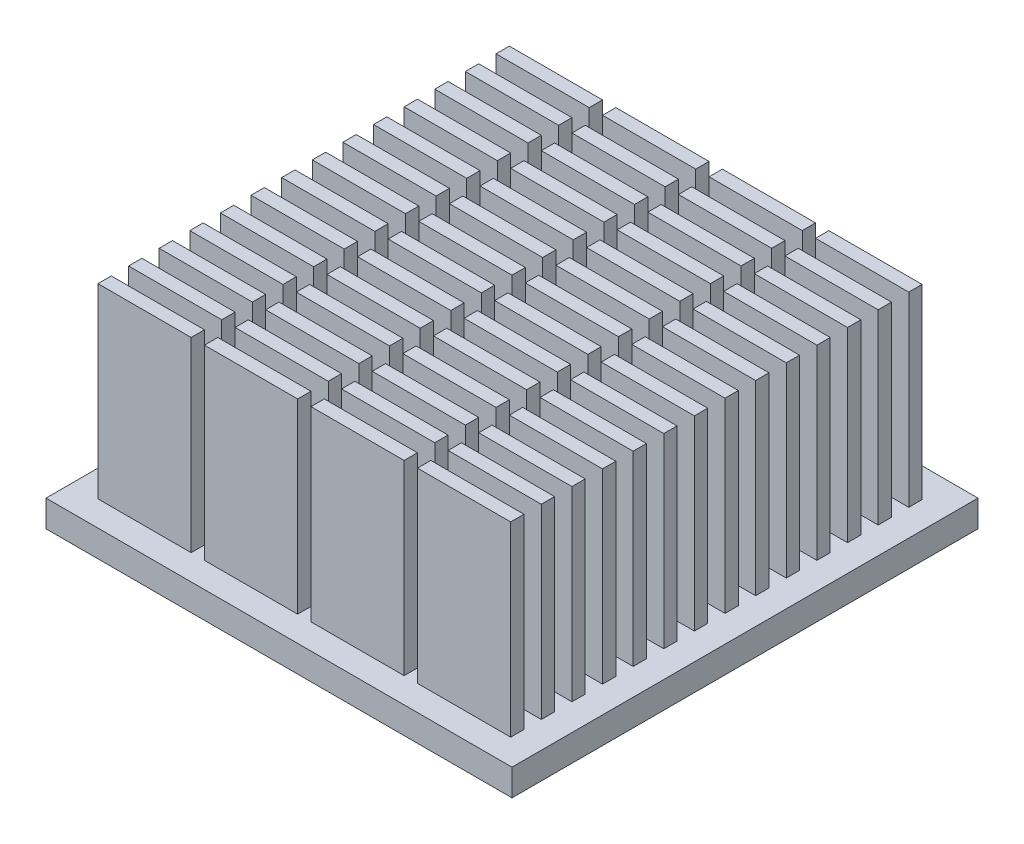
from build123d import *

# Parameters (mm, degrees)
SKETCH1_W           = 35
SKETCH1_H           = 35
BOSS_EXTRUDE1_DEPTH = 2
SKETCH2_W           = 7
SKETCH2_H           = 1
BOSS_EXTRUDE2_DEPTH = 14


with BuildPart() as part:
    # Sketch1 → Boss-Extrude1 (new body)
    with BuildSketch(Plane(origin=(0, 0, 0), x_dir=(1, 0, 0), z_dir=(0, 1, 0))):
        Rectangle(SKETCH1_W, SKETCH1_H)
    extrude(amount=BOSS_EXTRUDE1_DEPTH)

    # Sketch2 → Boss-Extrude2 (add)
    with BuildSketch(Plane(origin=(0, 2, 0), x_dir=(1, 0, 0), z_dir=(0, 1, 0))):
        with Locations((-12, -1.3)):
            Rectangle(SKETCH2_W, SKETCH2_H)
        with Locations((-12, 1)):
            Rectangle(SKETCH2_W, SKETCH2_H)
        with Locations((-4, 1)):
            Rectangle(SKETCH2_W, SKETCH2_H)
        with Locations((4, 1)):
            Rectangle(SKETCH2_W, SKETCH2_H)
        with Locations((12, 1)):
            Rectangle(SKETCH2_W, SKETCH2_H)
        with Locations((-4, -1.3)):
            Rectangle(SKETCH2_W, SKETCH2_H)
        with Locations((4, -1.3)):
            Rectangle(SKETCH2_W, SKETCH2_H)
        with Locations((12, -1.3)):
            Rectangle(SKETCH2_W, SKETCH2_H)
        with Locations((-12, -3.6)):
            Rectangle(SKETCH2_W, SKETCH2_H)
        with Locations((-4, -3.6)):
            Rectangle(SKETCH2_W, SKETCH2_H)
        with Locations((4, -3.6)):
            Rectangle(SKETCH2_W, SKETCH2_H)
        with Locations((12, -3.6)):
            Rectangle(SKETCH2_W, SKETCH2_H)
        with Locations((-12, -5.9)):
            Rectangle(SKETCH2_W, SKETCH2_H)
        with Locations((-4, -5.9)):
            Rectangle(SKETCH2_W, SKETCH2_H)
        with Locations((4, -5.9)):
            Rectangle(SKETCH2_W, SKETCH2_H)
        with Locations((12, -5.9)):
            Rectangle(SKETCH2_W, SKETCH2_H)
        with Locations((-12, -8.2)):
            Rectangle(SKETCH2_W, SKETCH2_H)
        with Locations((-4, -8.2)):
            Rectangle(SKETCH2_W, SKETCH2_H)
        with Locations((4, -8.2)):
            Rectangle(SKETCH2_W, SKETCH2_H)
        with Locations((12, -8.2)):
            Rectangle(SKETCH2_W, SKETCH2_H)
        with Locations((-12, -10.5)):
            Rectangle(SKETCH2_W, SKETCH2_H)
        with Locations((-4, -10.5)):
            Rectangle(SKETCH2_W, SKETCH2_H)
        with Locations((4, -10.5)):
            Rectangle(SKETCH2_W, SKETCH2_H)
        with Locations((12, -10.5)):
            Rectangle(SKETCH2_W, SKETCH2_H)
        with Locations((-12, -12.8)):
            Rectangle(SKETCH2_W, SKETCH2_H)
        with Locations((-4, -12.8)):
            Rectangle(SKETCH2_W, SKETCH2_H)
        with Locations((4, -12.8)):
            Rectangle(SKETCH2_W, SKETCH2_H)
        with Locations((12, -12.8)):
            Rectangle(SKETCH2_W, SKETCH2_H)
        with Locations((-12, -15.1)):
            Rectangle(SKETCH2_W, SKETCH2_H)
        with Locations((-4, -15.1)):
            Rectangle(SKETCH2_W, SKETCH2_H)
        with Locations((4, -15.1)):
            Rectangle(SKETCH2_W, SKETCH2_H)
        with Locations((12, -15.1)):
            Rectangle(SKETCH2_W, SKETCH2_H)
        with Locations((-12, 3.3)):
            Rectangle(SKETCH2_W, SKETCH2_H)
        with Locations((-4, 3.3)):
            Rectangle(SKETCH2_W, SKETCH2_H)
        with Locations((4, 3.3)):
            Rectangle(SKETCH2_W, SKETCH2_H)
        with Locations((12, 3.3)):
            Rectangle(SKETCH2_W, SKETCH2_H)
        with Locations((-12, 5.6)):
            Rectangle(SKETCH2_W, SKETCH2_H)
        with Locations((-4, 5.6)):
            Rectangle(SKETCH2_W, SKETCH2_H)
        with Locations((4, 5.6)):
            Rectangle(SKETCH2_W, SKETCH2_H)
        with Locations((12, 5.6)):
            Rectangle(SKETCH2_W, SKETCH2_H)
        with Locations((-12, 7.9)):
            Rectangle(SKETCH2_W, SKETCH2_H)
        with Locations((-4, 7.9)):
            Rectangle(SKETCH2_W, SKETCH2_H)
        with Locations((4, 7.9)):
            Rectangle(SKETCH2_W, SKETCH2_H)
        with Locations((12, 7.9)):
            Rectangle(SKETCH2_W, SKETCH2_H)
        with Locations((-12, 10.2)):
            Rectangle(SKETCH2_W, SKETCH2_H)
        with Locations((-4, 10.2)):
            Rectangle(SKETCH2_W, SKETCH2_H)
        with Locations((4, 10.2)):
            Rectangle(SKETCH2_W, SKETCH2_H)
        with Locations((12, 10.2)):
            Rectangle(SKETCH2_W, SKETCH2_H)
        with Locations((-12, 12.5)):
            Rectangle(SKETCH2_W, SKETCH2_H)
        with Locations((-4, 12.5)):
            Rectangle(SKETCH2_W, SKETCH2_H)
        with Locations((4, 12.5)):
            Rectangle(SKETCH2_W, SKETCH2_H)
        with Locations((12, 12.5)):
            Rectangle(SKETCH2_W, SKETCH2_H)
        with Locations((-12, 14.8)):
            Rectangle(SKETCH2_W, SKETCH2_H)
        with Locations((-4, 14.8)):
            Rectangle(SKETCH2_W, SKETCH2_H)
        with Locations((4, 14.8)):
            Rectangle(SKETCH2_W, SKETCH2_H)
        with Locations((12, 14.8)):
            Rectangle(SKETCH2_W, SKETCH2_H)
    extrude(amount=BOSS_EXTRUDE2_DEPTH)


solid = part.part
